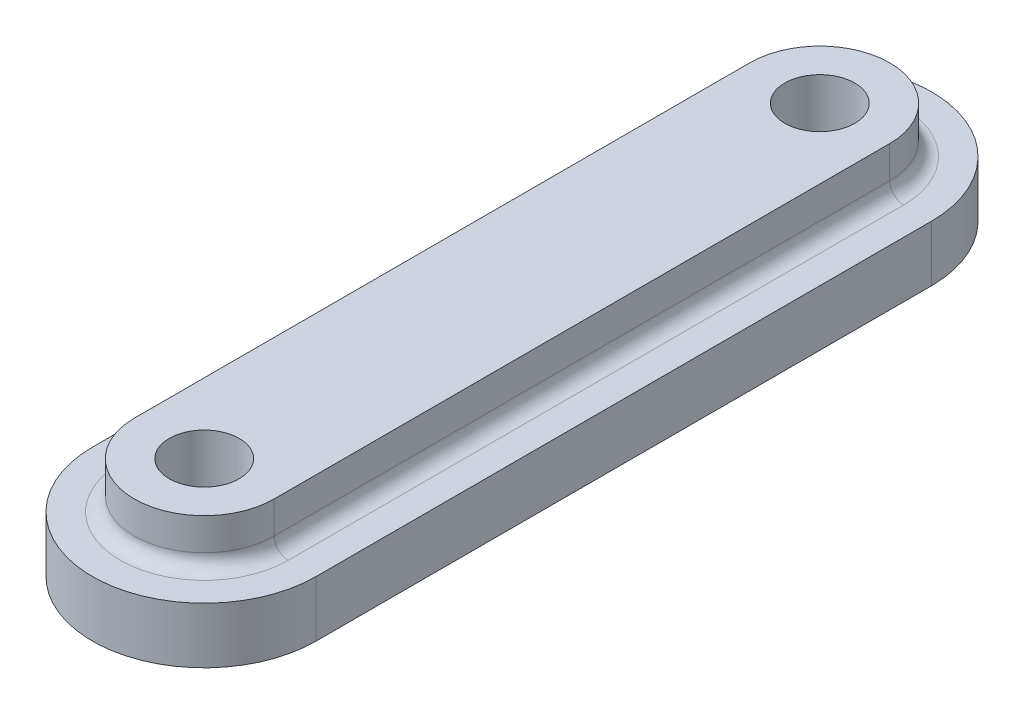
from build123d import *

# Parameters (mm, degrees)
BOSS_EXTRUDE1_DEPTH            = 2
BOSS_EXTRUDE2_DEPTH            = 1.65
F_2_5_2_5_DIAMETER_HOLE1_D     = 2.5
F_2_5_2_5_DIAMETER_HOLE1_DEPTH = 3.65
FILLET1_R                      = 0.5


with BuildPart() as part:
    # Sketch1 → Boss-Extrude1 (new body)
    with BuildSketch(Plane(origin=(0, -0.825, 0), x_dir=(1, 0, 0), z_dir=(0, 1, 0))):
        with BuildLine():
            Line((42, -11), (42, 11))
            ThreePointArc((42, 11), (38, 15), (34, 11))
            Line((34, 11), (34, -11))
            ThreePointArc((34, -11), (38, -15), (42, -11))
        make_face()
    extrude(amount=-BOSS_EXTRUDE1_DEPTH)

    # Sketch2 → Boss-Extrude2 (add)
    with BuildSketch(Plane(origin=(0, -0.825, 0), x_dir=(-1, 0, 0), z_dir=(0, 1, 0))):
        with BuildLine():
            Line((-35.5, 11), (-35.5, -11))
            ThreePointArc((-35.5, -11), (-38, -13.5), (-40.5, -11))
            Line((-40.5, -11), (-40.5, 11))
            ThreePointArc((-40.5, 11), (-38, 13.5), (-35.5, 11))
        make_face()
    extrude(amount=BOSS_EXTRUDE2_DEPTH)

    # Ø2.5 (2.5) Diameter Hole1
    with Locations(Plane(origin=(0, 0.825, 0), x_dir=(1, 0, 0), z_dir=(0, 1, 0))):
        with Locations((38, -11), (38, 11)):
            Hole(F_2_5_2_5_DIAMETER_HOLE1_D / 2, depth=F_2_5_2_5_DIAMETER_HOLE1_DEPTH)

    # Fillet1
    fillet1_edges = [part.edges().sort_by_distance(p)[0] for p in [
        (38, -0.825, 13.5),
        (40.5, -0.825, 0),
        (38, -0.825, -13.5),
        (35.5, -0.825, 0),
    ]]
    fillet(fillet1_edges, radius=FILLET1_R)


solid = part.part
